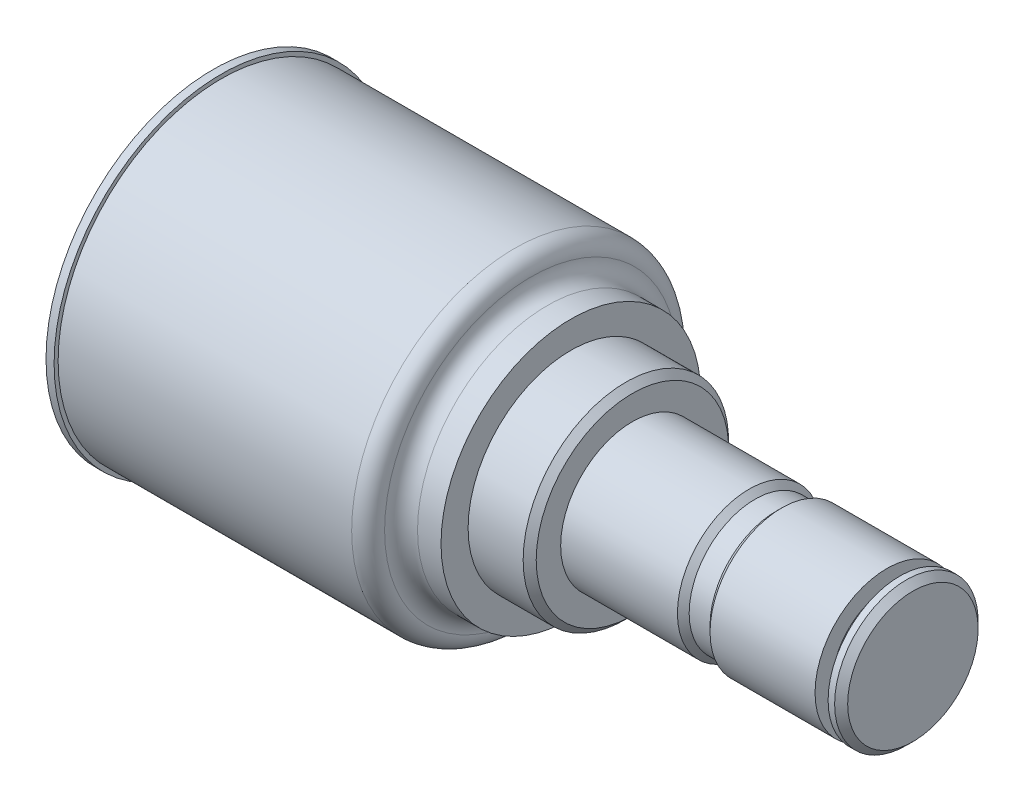
from build123d import *

# Parameters (mm, degrees)
CHAMFER1_SIZE = 1.27


with BuildPart() as part:
    # Sketch1 → Revolve1 (revolve)
    with BuildSketch(Plane.XY):
        with BuildLine():
            Line((0, 0), (0, 32.5374))
            Line((0, 32.5374), (1.5748, 32.5374))
            Line((1.5748, 32.5374), (1.5748, 31.75))
            Line((1.5748, 31.75), (58.7248, 31.75))
            ThreePointArc((58.7248, 31.75), (60.991879668, 30.797830353), (61.899183307, 28.512425058))
            ThreePointArc((61.899183307, 28.512425058), (62.806486945, 26.227019762), (65.073566613, 25.274850115))
            Line((65.073566613, 25.274850115), (69.6468, 25.274850115))
            Line((69.6468, 25.274850115), (69.6468, 20.0025))
            Line((69.6468, 20.0025), (81.6356, 20.0025))
            Line((81.6356, 20.0025), (81.6356, 13.97))
            Line((81.6356, 13.97), (104.3686, 13.97))
            Line((104.3686, 13.97), (105.5116, 12.827))
            Line((105.5116, 12.827), (109.5756, 12.827))
            Line((109.5756, 12.827), (110.7186, 13.97))
            Line((110.7186, 13.97), (131.1656, 13.97))
            Line((131.1656, 13.97), (131.1656, 10.5918))
            Line((131.1656, 10.5918), (133.7056, 10.5918))
            Line((133.7056, 10.5918), (133.7056, 13.97))
            Line((133.7056, 13.97), (136.2456, 13.97))
            Line((136.2456, 13.97), (136.2456, 0))
            Line((136.2456, 0), (0, 0))
        make_face()
    revolve(axis=Axis((-9.339404577, 0, 0), (1, 0, 0)))

    # Chamfer1
    chamfer1_edges = [part.edges().sort_by_distance(p)[0] for p in [
        (81.6356, -20.0025, 0),
        (136.2456, -13.97, 0),
    ]]
    chamfer(chamfer1_edges, length=CHAMFER1_SIZE)


solid = part.part
